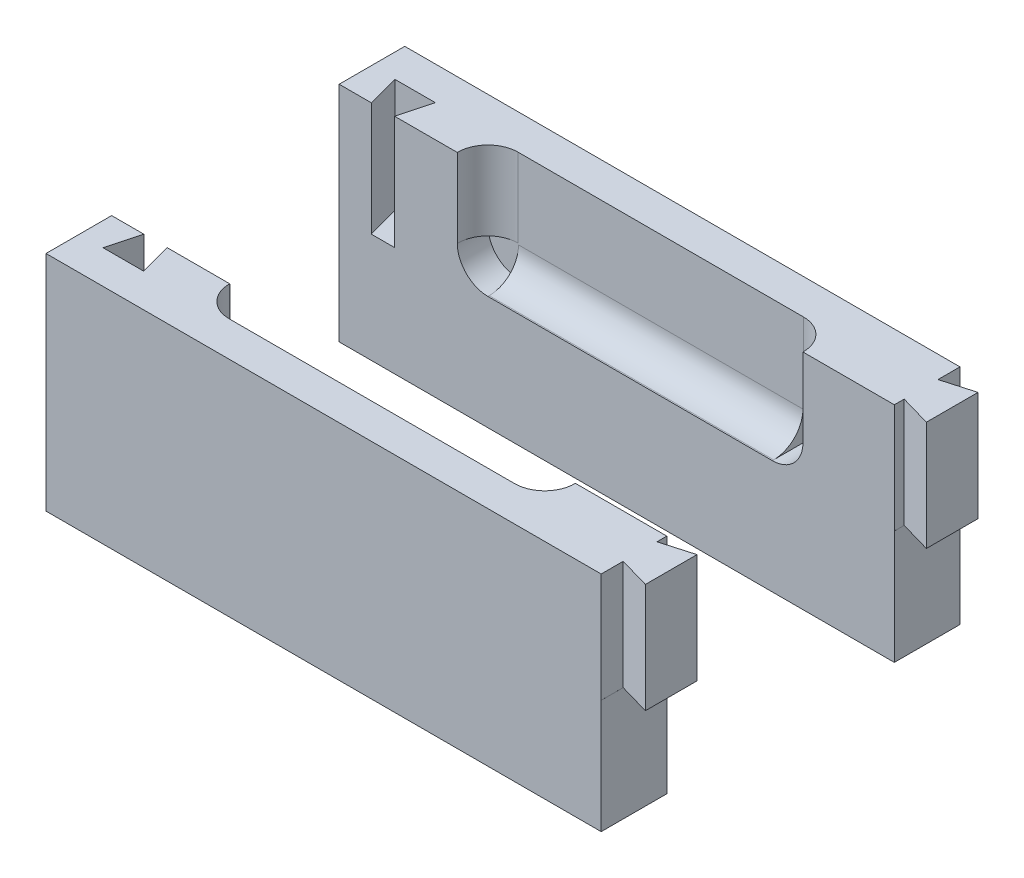
from build123d import *

# Parameters (mm, degrees)
SKETCH1_W               = 134
SKETCH1_H               = 51
BOSS_EXTRUDE1_DEPTH     = 15
CUT_EXTRUDE6_DEPTH      = 65
CUT_EXTRUDE2_DEPTH      = 1
CUT_EXTRUDE2_DEPTH_BACK = 26
CUT_EXTRUDE4_DEPTH      = 25
SKETCH7_W               = 7.11
SKETCH7_H               = 15
CUT_EXTRUDE5_DEPTH      = 26
CUT_EXTRUDE7_DEPTH      = 18
CUT_EXTRUDE8_DEPTH      = 7


with BuildPart() as part:
    # Sketch1 → Boss-Extrude1 (new body)
    with BuildSketch(Plane.XY):
        with Locations((6.063380282, 3.112676056)):
            Rectangle(SKETCH1_W, SKETCH1_H)
    extrude(amount=BOSS_EXTRUDE1_DEPTH)

    # Sketch8 → Cut-Extrude6 (cut)
    with BuildSketch(Plane(origin=(38.063380282, 0, 0), x_dir=(0, 0, -1), z_dir=(1, 0, 0))):
        with BuildLine():
            Line((-7, 28.612676056), (0, 28.612676056))
            Line((0, 28.612676056), (0, 3.612676056))
            Line((0, 3.612676056), (-0.3, 3.612676056))
            ThreePointArc((-0.3, 3.612676056), (-5.037615434, 5.575060622), (-7, 10.312676056))
            Line((-7, 10.312676056), (-7, 28.612676056))
        make_face()
    extrude(amount=-CUT_EXTRUDE6_DEPTH, mode=Mode.SUBTRACT)

    # Sketch3 → Cut-Extrude2 (cut, two sides)
    with BuildSketch(Plane(origin=(0, 28.612676056, 0), x_dir=(1, 0, 0), z_dir=(0, 1, 0))) as cut_extrude2_sk:
        Polygon((-340.610496837, 0), (-60.936619718, 0), (-53.586619718, 0), (-55.553644461, -7.34103628), (-46.319594976, -7.34103628), (-48.286619718, 0), (-120.671545534, 270.144220847), (-554.437861933, 623.29672746), (-774.376813236, 353.152506613), align=None)
    extrude(amount=CUT_EXTRUDE2_DEPTH, mode=Mode.SUBTRACT)
    extrude(cut_extrude2_sk.sketch, amount=-CUT_EXTRUDE2_DEPTH_BACK, mode=Mode.SUBTRACT)

    # Sketch5 → Cut-Extrude4 (cut)
    with BuildSketch(Plane(origin=(0, 28.612676056, 0), x_dir=(1, 0, 0), z_dir=(0, 1, 0))):
        Polygon((65.950043732, 0), (73.063380282, 0), (73.063380282, -0.210283567), (65.950043732, -2.25), align=None)
        Polygon((65.950043732, -15), (65.950043732, -9.970567134), (73.063380282, -12.010283567), (73.063380282, -15), align=None)
    extrude(amount=-CUT_EXTRUDE4_DEPTH, mode=Mode.SUBTRACT)

    # Sketch7 → Cut-Extrude5 (cut)
    with BuildSketch(Plane.XZ.offset(22.387323944)):
        with Locations((69.508380282, 7.5)):
            Rectangle(SKETCH7_W, SKETCH7_H)
    extrude(amount=-CUT_EXTRUDE5_DEPTH, mode=Mode.SUBTRACT)

    # Sketch9 → Cut-Extrude7 (cut)
    with BuildSketch(Plane(origin=(0, 28.612676056, 0), x_dir=(1, 0, 0), z_dir=(0, 1, 0))):
        with BuildLine():
            Line((-26.936619718, -7), (-27.036619718, -7))
            ThreePointArc((-27.036619718, -7), (-31.915656508, -4.97903679), (-33.936619718, -0.1))
            Line((-33.936619718, -0.1), (-33.936619718, 0))
            Line((-33.936619718, 0), (-26.936619718, 0))
            Line((-26.936619718, 0), (-26.936619718, -7))
        make_face()
        with BuildLine():
            Line((38.063380282, -7), (38.163380282, -7))
            ThreePointArc((38.163380282, -7), (43.042417072, -4.97903679), (45.063380282, -0.1))
            Line((45.063380282, -0.1), (45.063380282, 0))
            Line((45.063380282, 0), (38.063380282, 0))
            Line((38.063380282, 0), (38.063380282, -7))
        make_face()
    extrude(amount=-CUT_EXTRUDE7_DEPTH, mode=Mode.SUBTRACT)

    # Sketch12 → Cut-Extrude8 (cut)
    with BuildSketch(Plane(origin=(0, 0, 0), x_dir=(-1, 0, 0), z_dir=(0, 0, -1))):
        with BuildLine():
            ThreePointArc((-45.063380282, 10.612676056), (-43.01312775, 5.662928588), (-38.063380282, 3.612676056))
            Line((-38.063380282, 3.612676056), (-38.063380282, 10.612676056))
            Line((-38.063380282, 10.612676056), (-45.063380282, 10.612676056))
        make_face()
        with BuildLine():
            ThreePointArc((33.936619718, 10.612676056), (31.886367187, 5.662928588), (26.936619718, 3.612676056))
            Line((26.936619718, 3.612676056), (26.936619718, 10.612676056))
            Line((26.936619718, 10.612676056), (33.936619718, 10.612676056))
        make_face()
    extrude(amount=-CUT_EXTRUDE8_DEPTH, mode=Mode.SUBTRACT)


with BuildPart() as body_2:
    # Mirror2: mirrored copy
    add(part.part.mirror(Plane(origin=(0, 0, -26), x_dir=(1, 0, 0), z_dir=(0, 0, -1))))


solid = Compound([part.part, body_2.part])
